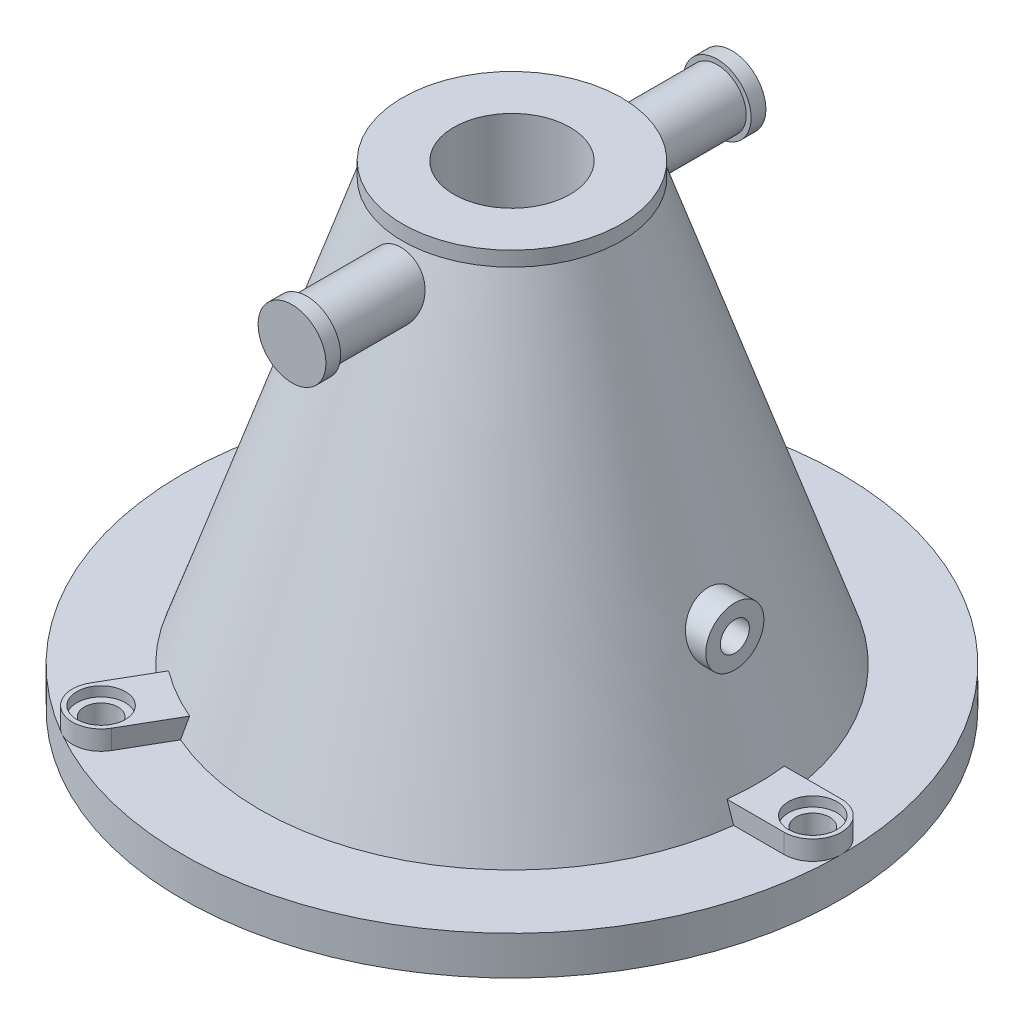
from build123d import *

# Parameters (mm, degrees)
SWEEP1_PROFILE_R     = 0.75
CUT_SWEEP1_PROFILE_R = 0.375
SWEEP5_PROFILE_R     = 0.75
SKETCH42_R           = 0.875
BOSS_EXTRUDE1_DEPTH  = 0.38
BOSS_EXTRUDE2_START  = 1
BOSS_EXTRUDE2_DEPTH  = 0.5
CUT_EXTRUDE1_START   = 1.5
SKETCH45_R           = 0.625
CUT_EXTRUDE1_DEPTH   = 0.25
CUT_EXTRUDE3_START   = -1.0000001
SKETCH47_R           = 0.435
CUT_EXTRUDE3_DEPTH   = 14.2500001
CIRPATTERN1_COUNT    = 3


with BuildPart() as part:
    # Sketch1 → Revolve1 (revolve)
    with BuildSketch(Plane.XY):
        with BuildLine():
            Line((8.5, 0), (8.5, 1))
            Line((8.5, 1), (6.5, 1))
            Line((6.5, 1), (2.825, 11.87))
            Line((2.825, 11.87), (2.825, 12.25))
            Line((2.825, 12.25), (1.5, 12.25))
            Line((1.5, 12.25), (1.5, 3.25))
            Line((1.5, 3.25), (2.25, 3.25))
            Line((2.25, 3.25), (2.375, 8.206991452))
            ThreePointArc((2.375, 8.206991452), (2.799921643, 8.688742215), (3.348503009, 8.354525689))
            Line((3.348503009, 8.354525689), (6.173055163, 0))
            Line((6.173055163, 0), (8.5, 0))
        make_face()
    revolve(axis=Axis((0, -0.442438554, 0), (0, 1, 0)))

    # Sweep1: sweep along a path in Sketch5
    with BuildLine(Plane.XY) as sweep1_path:
        Line((4.13, 4.5), (5.75, 4.5))
    # Sweep1 profile (on start of the path) → Sweep1 (sweep)
    with BuildSketch(Plane(origin=(4.13, 4.5, 0), x_dir=(0, 0, 1), z_dir=(1, 0, 0))):
        Circle(SWEEP1_PROFILE_R)
    sweep(path=sweep1_path.line)

    # Cut-Sweep1: sweep along a path in Sketch5_2
    with BuildLine(Plane.XY) as cut_sweep1_path:
        Line((4.13, 4.5), (5.75, 4.5))
    # Cut-Sweep1 profile (on start of the path) → Cut-Sweep1 (sweep, cut)
    with BuildSketch(Plane(origin=(4.13, 4.5, 0), x_dir=(0, 0, 1), z_dir=(1, 0, 0))):
        Circle(CUT_SWEEP1_PROFILE_R)
    sweep(path=cut_sweep1_path.line, mode=Mode.SUBTRACT)

    # Sweep5: sweep along a path in Sketch16
    with BuildLine(Plane(origin=(0, 0, 0), x_dir=(0, 0, -1), z_dir=(1, 0, 0))) as sweep5_path:
        Line((2.375, 11), (5.675, 11))
    # Sweep5 profile (on start of the path) → Sweep5 (sweep)
    with BuildSketch(Plane(origin=(0, 11, -2.375), x_dir=(-1, 0, 0), z_dir=(0, 0, -1))):
        Circle(SWEEP5_PROFILE_R)
    sweep5 = sweep(path=sweep5_path.line)

    # Sketch42 → Boss-Extrude1 (add)
    with BuildSketch(Plane(origin=(0, 0, -5.675), x_dir=(-1, 0, 0), z_dir=(0, 0, -1))):
        with Locations((0, 11)):
            Circle(SKETCH42_R)
    boss_extrude1 = extrude(amount=-BOSS_EXTRUDE1_DEPTH)

    # Mirror2: Sweep5, Boss-Extrude1 across plane
    add(sweep5.mirror(Plane.XY))
    add(boss_extrude1.mirror(Plane.XY))

    # Sketch44 → Boss-Extrude2 (add)
    with BuildSketch(Plane(origin=(0, 0, 0), x_dir=(1, 0, 0), z_dir=(0, 1, 0)).offset(BOSS_EXTRUDE2_START)):
        with BuildLine():
            Line((7.76, 0.74), (6.26, 0.74))
            Line((6.26, 0.74), (6.26, -0.74))
            Line((6.26, -0.74), (7.76, -0.74))
            ThreePointArc((7.76, -0.74), (8.5, 0), (7.76, 0.74))
        make_face()
        with BuildLine():
            Line((-3.239141201, -7.090357133), (-2.489141201, -5.791319028))
            Line((-2.489141201, -5.791319028), (-3.770858799, -5.051319028))
            Line((-3.770858799, -5.051319028), (-4.520858799, -6.350357133))
            ThreePointArc((-4.520858799, -6.350357133), (-4.25, -7.361215932), (-3.239141201, -7.090357133))
        make_face()
        with BuildLine():
            Line((-4.520858799, 6.350357133), (-3.770858799, 5.051319028))
            Line((-3.770858799, 5.051319028), (-2.489141201, 5.791319028))
            Line((-2.489141201, 5.791319028), (-3.239141201, 7.090357133))
            ThreePointArc((-3.239141201, 7.090357133), (-4.25, 7.361215932), (-4.520858799, 6.350357133))
        make_face()
    extrude(amount=BOSS_EXTRUDE2_DEPTH)

    # Sketch45 → Cut-Extrude1 (cut)
    with BuildSketch(Plane(origin=(0, 0, 0), x_dir=(1, 0, 0), z_dir=(0, 1, 0)).offset(CUT_EXTRUDE1_START)):
        with Locations((7.76, 0)):
            Circle(SKETCH45_R)
    cut_extrude1 = extrude(amount=-CUT_EXTRUDE1_DEPTH, mode=Mode.SUBTRACT)

    # Sketch47 → Cut-Extrude3 (cut)
    with BuildSketch(Plane(origin=(0, 0, 0), x_dir=(1, 0, 0), z_dir=(0, 1, 0)).offset(CUT_EXTRUDE3_START)):
        with Locations((7.76, 0)):
            Circle(SKETCH47_R)
    cut_extrude3 = extrude(amount=CUT_EXTRUDE3_DEPTH, mode=Mode.SUBTRACT)

    # CirPattern1: Cut-Extrude1, Cut-Extrude3 ×3 about axis
    cirpattern1_axis = Axis((0, 0, 0), (0, 1, 0))
    for i in range(1, CIRPATTERN1_COUNT):
        add(cut_extrude1.rotate(cirpattern1_axis, i * 360 / CIRPATTERN1_COUNT), mode=Mode.SUBTRACT)
        add(cut_extrude3.rotate(cirpattern1_axis, i * 360 / CIRPATTERN1_COUNT), mode=Mode.SUBTRACT)


solid = part.part
